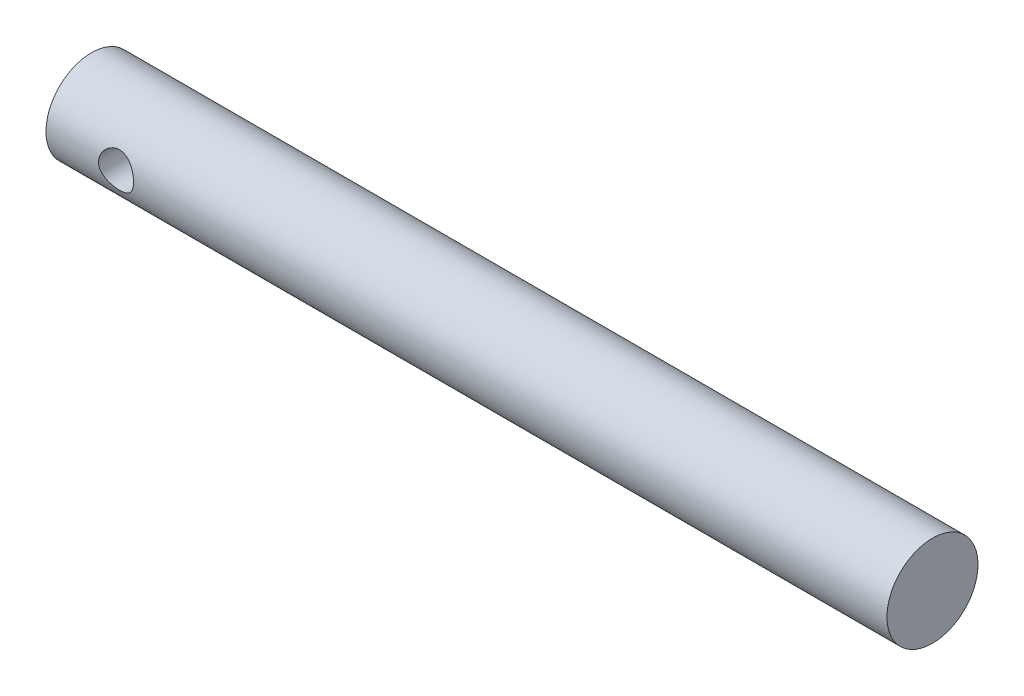
from build123d import *

# Parameters (mm, degrees)
CUT_EXTRUDE1_DEPTH      = 19.210024712
CUT_EXTRUDE1_DEPTH_BACK = 19.210024712
SKETCH2_3_R             = 0.75


with BuildPart() as part:
    # Sketch2 → Revolve2 (revolve)
    with BuildSketch(Plane.XY):
        with BuildLine():
            Line((18, 0), (-14.25, 0))
            ThreePointArc((-14.25, 0), (-15, -0.75), (-15.75, 0))
            Line((-15.75, 0), (-18, 0))
            Line((-18, 0), (-18, -1.95))
            Line((-18, -1.95), (18, -1.95))
            Line((18, -1.95), (18, 0))
        make_face()
    revolve(axis=Axis((-18, 0, 0), (1, 0, 0)))

    # Sketch2_3 → Cut-Extrude1 (cut, two sides: drawn at the far end of the back side and taken through both)
    with BuildSketch(Plane.XY.offset(-CUT_EXTRUDE1_DEPTH_BACK)):
        with Locations((-15, 0)):
            Circle(SKETCH2_3_R)
    extrude(amount=CUT_EXTRUDE1_DEPTH + CUT_EXTRUDE1_DEPTH_BACK, mode=Mode.SUBTRACT)


solid = part.part
